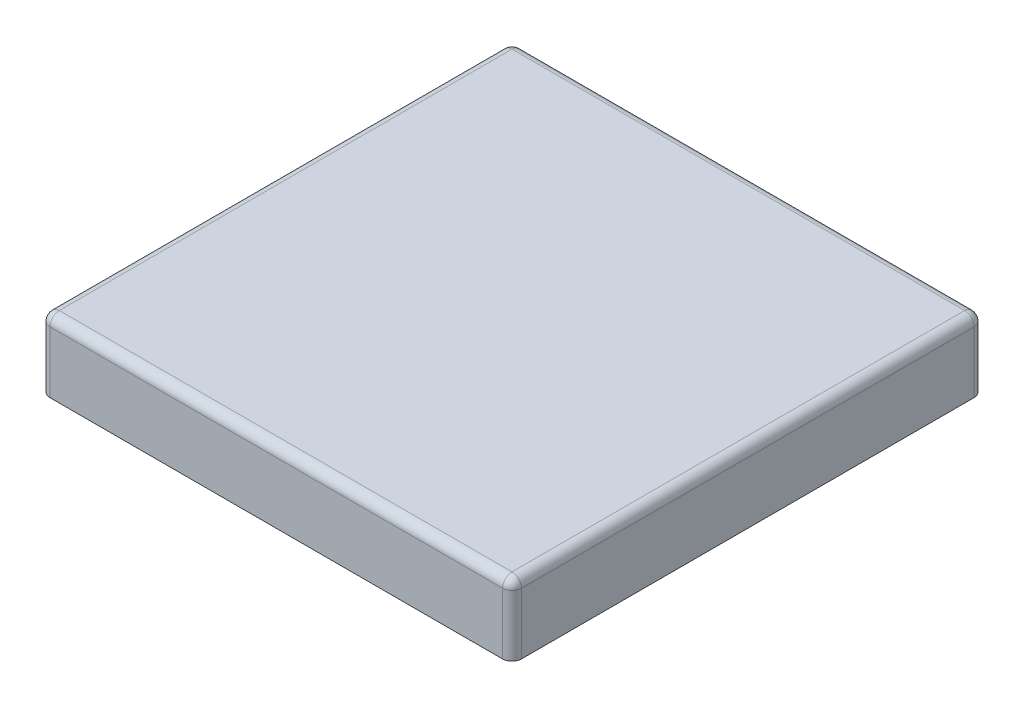
from build123d import *

# Parameters (mm, degrees)
SKETCH1_W               = 1000
SKETCH1_H               = 1000
BOSS_EXTRUDE1_DEPTH     = 150
SKETCH2_R               = 300
CUT_EXTRUDE1_DEPTH      = 100
FILLET1_R               = 20
SKETCH3_R               = 10
CUT_EXTRUDE2_DEPTH      = 100
MIRROR2_COPY_1_SKETCH_R = 10
MIRROR2_COPY_1_DEPTH    = 100


with BuildPart() as part:
    # Sketch1 → Boss-Extrude1 (new body)
    with BuildSketch(Plane(origin=(0, 0, 0), x_dir=(1, 0, 0), z_dir=(0, 1, 0))):
        Rectangle(SKETCH1_W, SKETCH1_H)
    extrude(amount=BOSS_EXTRUDE1_DEPTH)

    # Sketch2 → Cut-Extrude1 (cut)
    with BuildSketch(Plane.XZ):
        Circle(SKETCH2_R)
    extrude(amount=-CUT_EXTRUDE1_DEPTH, mode=Mode.SUBTRACT)

    # Fillet1
    fillet1_edges = [part.edges().sort_by_distance(p)[0] for p in [
        (500, 150, 0),
        (0, 150, -500),
        (-500, 150, 0),
        (-500, 75, -500),
        (500, 75, -500),
        (500, 75, 500),
        (-500, 75, 500),
        (0, 150, 500),
    ]]
    fillet(fillet1_edges, radius=FILLET1_R)

    # Sketch3 → Cut-Extrude2 (cut)
    with BuildSketch(Plane.XZ):
        with Locations((-460, -400)):
            Circle(SKETCH3_R)
    cut_extrude2 = extrude(amount=-CUT_EXTRUDE2_DEPTH, mode=Mode.SUBTRACT)

    # Mirror1: Cut-Extrude2 across plane
    add(cut_extrude2.mirror(Plane(origin=(0, 0, 0), x_dir=(0, 0, 1), z_dir=(1, 0, 0))), mode=Mode.SUBTRACT)

    # Mirror2: Cut-Extrude2 across plane
    add(cut_extrude2.mirror(Plane.XY), mode=Mode.SUBTRACT)

    # Mirror2 copy 1 sketch → Mirror2 copy 1 (cut)
    with BuildSketch(Plane(origin=(0, 0, 0), x_dir=(-1, 0, 0), z_dir=(0, -1, 0))):
        with Locations((-460, -400)):
            Circle(MIRROR2_COPY_1_SKETCH_R)
    extrude(amount=-MIRROR2_COPY_1_DEPTH, mode=Mode.SUBTRACT)


solid = part.part
